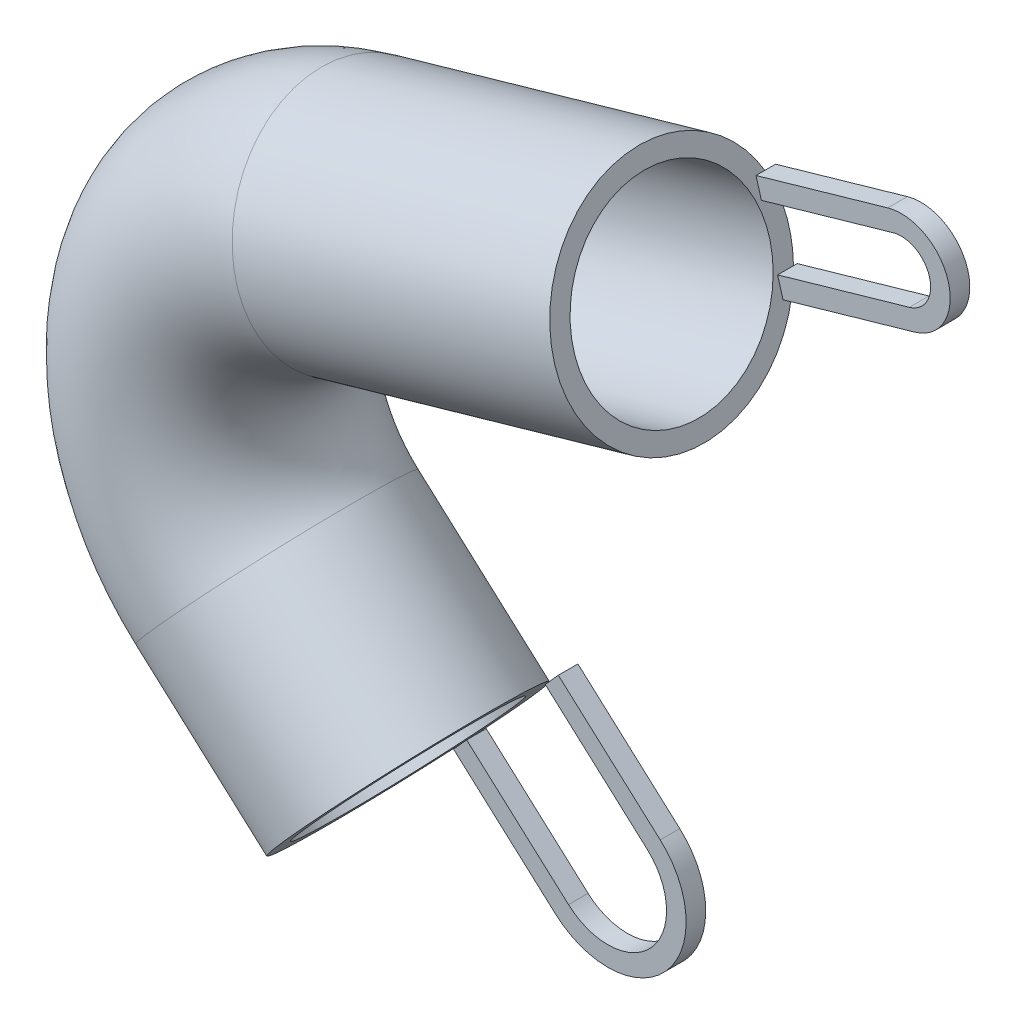
from build123d import *

# Parameters (mm, degrees)
VARREDURA_FINO1_PROFILE_R   = 6
VARREDURA_FINO1_PROFILE_R_2 = 5
RESSALTO_EXTRUS_O1_DEPTH    = 1


with BuildPart() as part:
    # Varredura-Fino1: sweep along a path in Esbo_o1
    with BuildLine(Plane.XY) as varredura_fino1_path:
        Line((0, -13.453624047), (-6.689647316, -7.432941462))
        ThreePointArc((-6.689647316, -7.432941462), (-9.74420246, 2.247335849), (-2.758518872, 9.612001541))
        Line((-2.758518872, 9.612001541), (13.460564792, 14.266666669))
    # Varredura-Fino1 profile (on start of the path) → Varredura-Fino1 (sweep)
    with BuildSketch(Plane(origin=(0, -13.453624047, 0), x_dir=(-0.6689647316224496, -0.7432941462471664, 0), z_dir=(-0.7432941462471664, 0.6689647316224496, 0))):
        Circle(VARREDURA_FINO1_PROFILE_R)
        Circle(VARREDURA_FINO1_PROFILE_R_2, mode=Mode.SUBTRACT)
    sweep(path=varredura_fino1_path.line)

    # Esbo_o19 → Ressalto-extrus_o1 (add)
    with BuildSketch(Plane(origin=(0, 0, -6), x_dir=(-1, 0, 0), z_dir=(0, 0, -1))):
        with BuildLine():
            Line((-13.046786961, 15.7084669), (-12.770935074, 16.669667054))
            Line((-12.770935074, 16.669667054), (-19.499336153, 18.600630265))
            ThreePointArc((-19.499336153, 18.600630265), (-22.591966256, 16.887259598), (-20.878595589, 13.794629494))
            Line((-20.878595589, 13.794629494), (-14.15019451, 11.863666283))
            Line((-14.15019451, 11.863666283), (-13.874342623, 12.824866438))
            Line((-13.874342623, 12.824866438), (-20.602743702, 14.755829648))
            ThreePointArc((-20.602743702, 14.755829648), (-21.630766102, 16.61140771), (-19.77518804, 17.639430111))
            Line((-19.77518804, 17.639430111), (-13.046786961, 15.7084669))
        make_face()
        with BuildLine():
            Line((-2.006894195, -11.223741608), (-2.675858926, -10.480447462))
            Line((-2.675858926, -10.480447462), (-7.87891795, -15.163200583))
            ThreePointArc((-7.87891795, -15.163200583), (-8.176235609, -20.812236095), (-2.527200097, -21.109553753))
            Line((-2.527200097, -21.109553753), (2.675858926, -16.426800632))
            Line((2.675858926, -16.426800632), (2.006894195, -15.683506486))
            Line((2.006894195, -15.683506486), (-3.196164829, -20.366259607))
            ThreePointArc((-3.196164829, -20.366259607), (-7.432941462, -20.143271363), (-7.209953219, -15.90649473))
            Line((-7.209953219, -15.90649473), (-2.006894195, -11.223741608))
        make_face()
    extrude(amount=-RESSALTO_EXTRUS_O1_DEPTH)


solid = part.part
